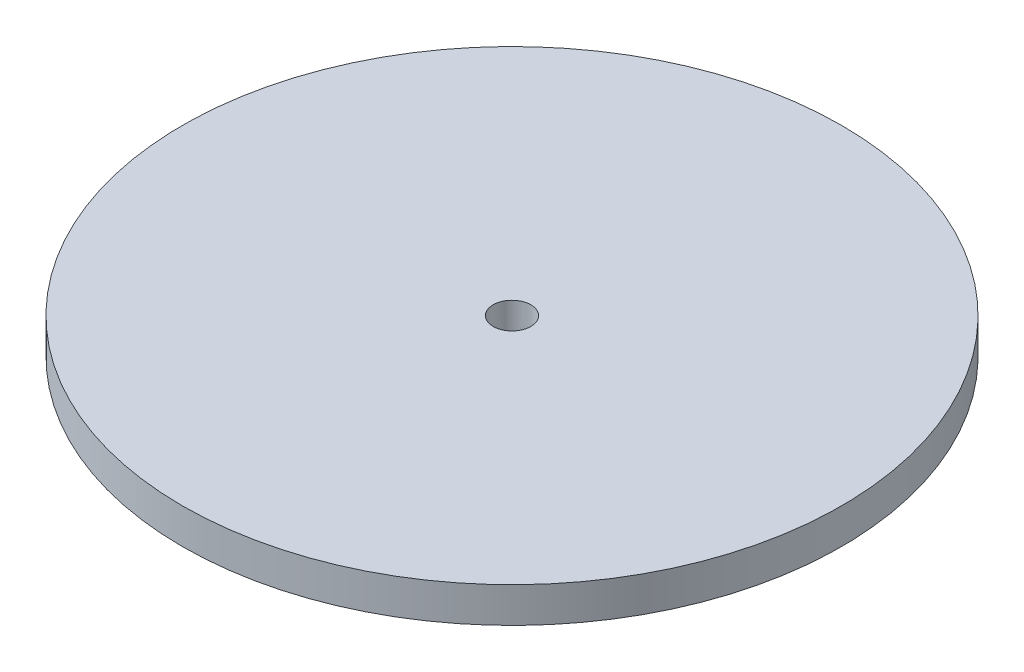
from build123d import *

# Parameters (mm, degrees)
SKETCH2_R           = 140
BOSS_EXTRUDE1_DEPTH = 15
SKETCH3_R           = 8
CUT_EXTRUDE1_DEPTH  = 16


with BuildPart() as part:
    # Sketch2 → Boss-Extrude1 (new body)
    with BuildSketch(Plane(origin=(0, 0, 0), x_dir=(1, 0, 0), z_dir=(0, 1, 0))):
        Circle(SKETCH2_R)
    extrude(amount=BOSS_EXTRUDE1_DEPTH)

    # Sketch3 → Cut-Extrude1 (cut, through all)
    with BuildSketch(Plane(origin=(0, 15, 0), x_dir=(1, 0, 0), z_dir=(0, 1, 0))):
        Circle(SKETCH3_R)
    extrude(amount=-CUT_EXTRUDE1_DEPTH, mode=Mode.SUBTRACT)


solid = part.part
